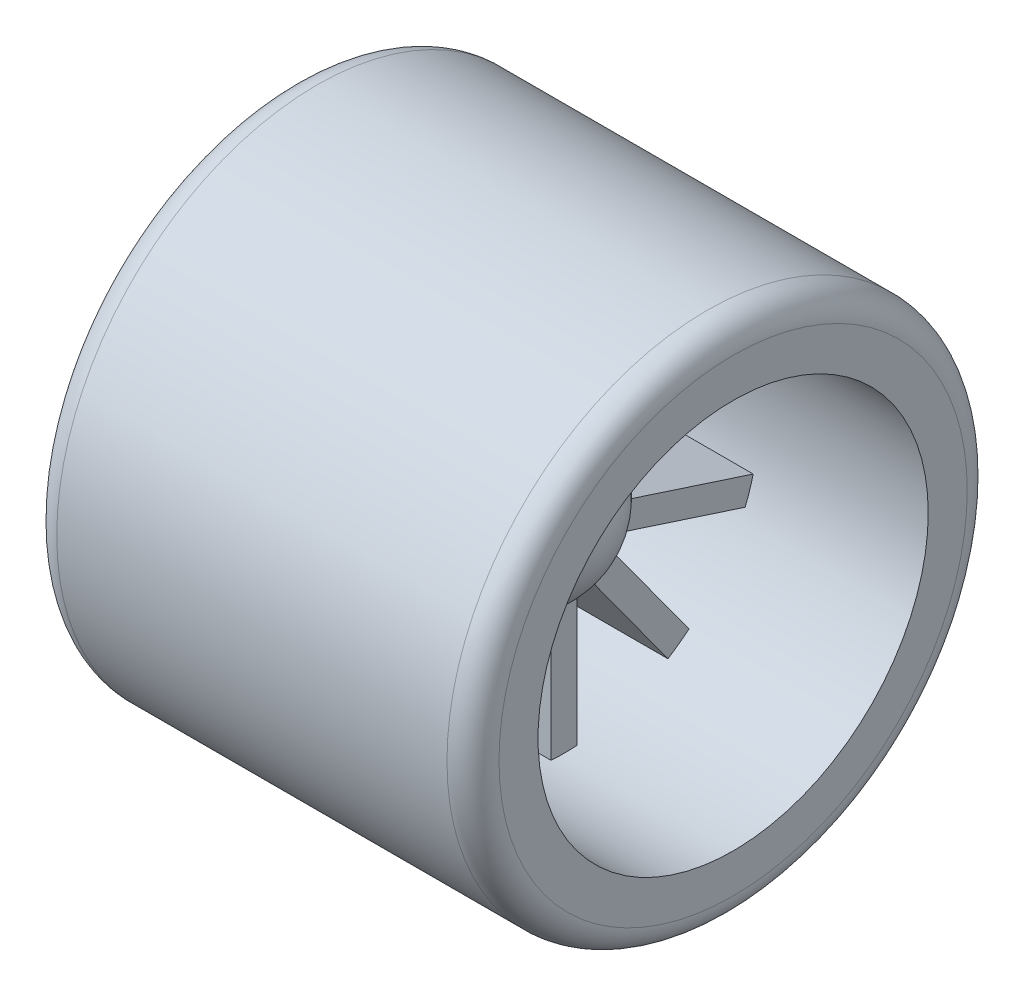
from build123d import *

# Parameters (mm, degrees)
SKETCH1_R           = 25.4
SKETCH1_R_2         = 19.05
BOSS_EXTRUDE1_DEPTH = 21.59
FILLET1_R           = 2.54
SKETCH2_W           = 2.54
SKETCH2_H           = 17.90600611
BOSS_EXTRUDE2_DEPTH = 5.08


with BuildPart() as part:
    # Sketch1 → Boss-Extrude1 (new body, symmetric)
    with BuildSketch(Plane(origin=(0, 0, 0), x_dir=(0, 0, -1), z_dir=(1, 0, 0))):
        Circle(SKETCH1_R)
        Circle(SKETCH1_R_2, mode=Mode.SUBTRACT)
    extrude(amount=BOSS_EXTRUDE1_DEPTH, both=True)

    # Fillet1
    fillet1_edges = [part.edges().sort_by_distance(p)[0] for p in [
        (-21.59, 0, 25.4),
        (21.59, 0, 25.4),
    ]]
    fillet(fillet1_edges, radius=FILLET1_R)

    # Sketch2 → Boss-Extrude2 (add, symmetric)
    with BuildSketch(Plane(origin=(0, 0, 0), x_dir=(0, 0, -1), z_dir=(1, 0, 0))):
        with Locations((0, 13.871691905)):
            Rectangle(SKETCH2_W, SKETCH2_H)
        Polygon((1.863681184, 4.72579014), (3.918584349, 3.232815599), (14.443470668, 17.719078843), (12.388567502, 19.212053384), align=None)
        Polygon((4.285499499, 2.72780022), (5.070402665, 0.312116669), (22.100026457, 5.845376858), (21.315123291, 8.26106041), align=None)
        Polygon((5.070402665, -0.312116669), (4.285499499, -2.72780022), (21.315123291, -8.26106041), (22.100026457, -5.845376858), align=None)
        Polygon((3.918584349, -3.232815599), (1.863681184, -4.72579014), (12.388567502, -19.212053384), (14.443470668, -17.719078843), align=None)
        with Locations((0, -13.871691905)):
            Rectangle(SKETCH2_W, SKETCH2_H)
        Polygon((-1.863681184, -4.72579014), (-3.918584349, -3.232815599), (-14.443470668, -17.719078843), (-12.388567502, -19.212053384), align=None)
        Polygon((-4.285499499, -2.72780022), (-5.070402665, -0.312116669), (-22.100026457, -5.845376858), (-21.315123291, -8.26106041), align=None)
        Polygon((-5.070402665, 0.312116669), (-4.285499499, 2.72780022), (-21.315123291, 8.26106041), (-22.100026457, 5.845376858), align=None)
        Polygon((-3.918584349, 3.232815599), (-1.863681184, 4.72579014), (-12.388567502, 19.212053384), (-14.443470668, 17.719078843), align=None)
    extrude(amount=BOSS_EXTRUDE2_DEPTH, both=True)

    # Sketch3 → Revolve1 (revolve)
    with BuildSketch(Plane(origin=(0, 0, 0), x_dir=(0, 0, -1), z_dir=(1, 0, 0))):
        with BuildLine():
            Line((0, 8.255), (0, -8.255))
            ThreePointArc((0, -8.255), (8.255, 0), (0, 8.255))
        make_face()
    revolve(axis=Axis((0, 8.255, 0), (0, -1, 0)))


solid = part.part
